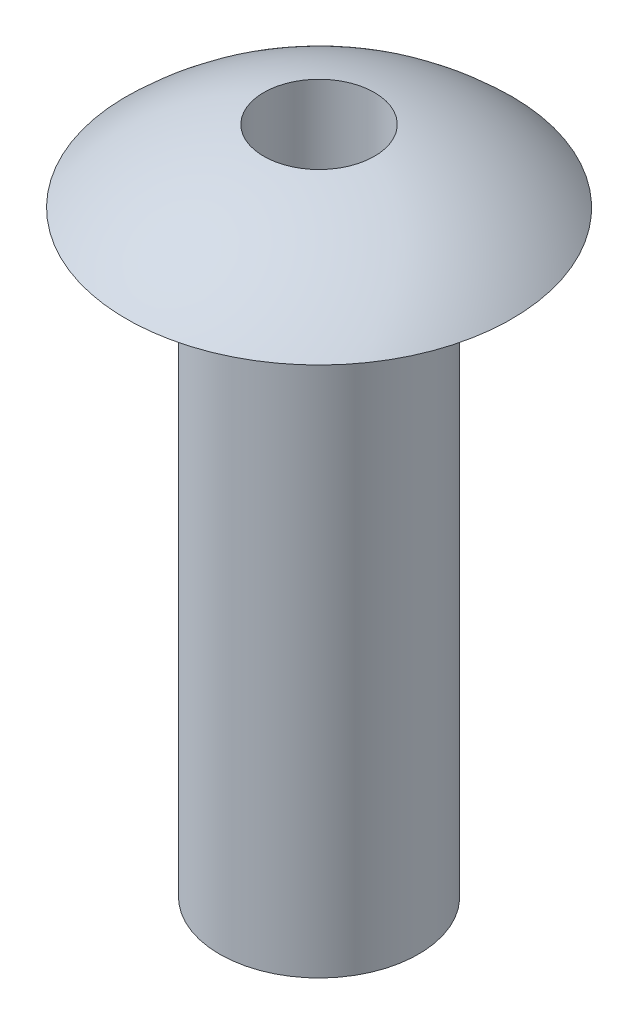
from build123d import *

# Parameters (mm, degrees)
SKETCH2_R          = 0.89
CUT_EXTRUDE1_DEPTH = 12.702243375


with BuildPart() as part:
    # Sketch1 → Revolve1 (revolve)
    with BuildSketch(Plane.XY):
        with BuildLine():
            Line((0, 0), (1.6, 0))
            Line((1.6, 0), (1.6, 9.6))
            Line((1.6, 9.6), (3.1, 9.6))
            ThreePointArc((3.1, 9.6), (1.671264491, 10.525735939), (0, 10.85))
            Line((0, 10.85), (0, 0))
        make_face()
    revolve(axis=Axis((0, 0, 0), (0, 1, 0)))

    # Sketch2 → Cut-Extrude1 (cut, through all)
    with BuildSketch(Plane.XZ):
        Circle(SKETCH2_R)
    extrude(amount=-CUT_EXTRUDE1_DEPTH, mode=Mode.SUBTRACT)


solid = part.part
